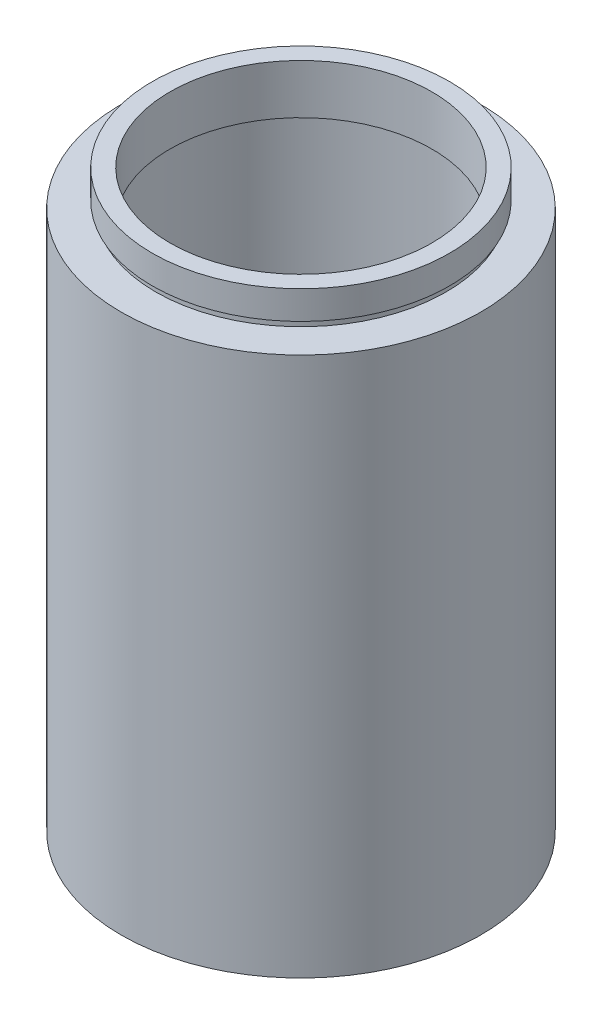
from build123d import *


with BuildPart() as part:
    # 草图1 → 旋转1 (revolve)
    with BuildSketch(Plane.XY, mode=Mode.PRIVATE) as revolve_1_sk:
        Polygon((18.5, 81.2), (21, 81.2), (21, 77.2), (20.5, 77.2), (20.5, 76.2), (25.4, 76.2), (25.4, 0), (20.5, 0), (20.5, 73.2), (21.1, 73.2), (21.1, 74.2), (18.5, 74.2), align=None)
    revolve(revolve_1_sk.sketch.rotate(Axis((0, 161.376166943, 0), (0, -1, 0)), 90), axis=Axis((0, 161.376166943, 0), (0, -1, 0)))  # turned: the seam where the file's is


solid = part.part
